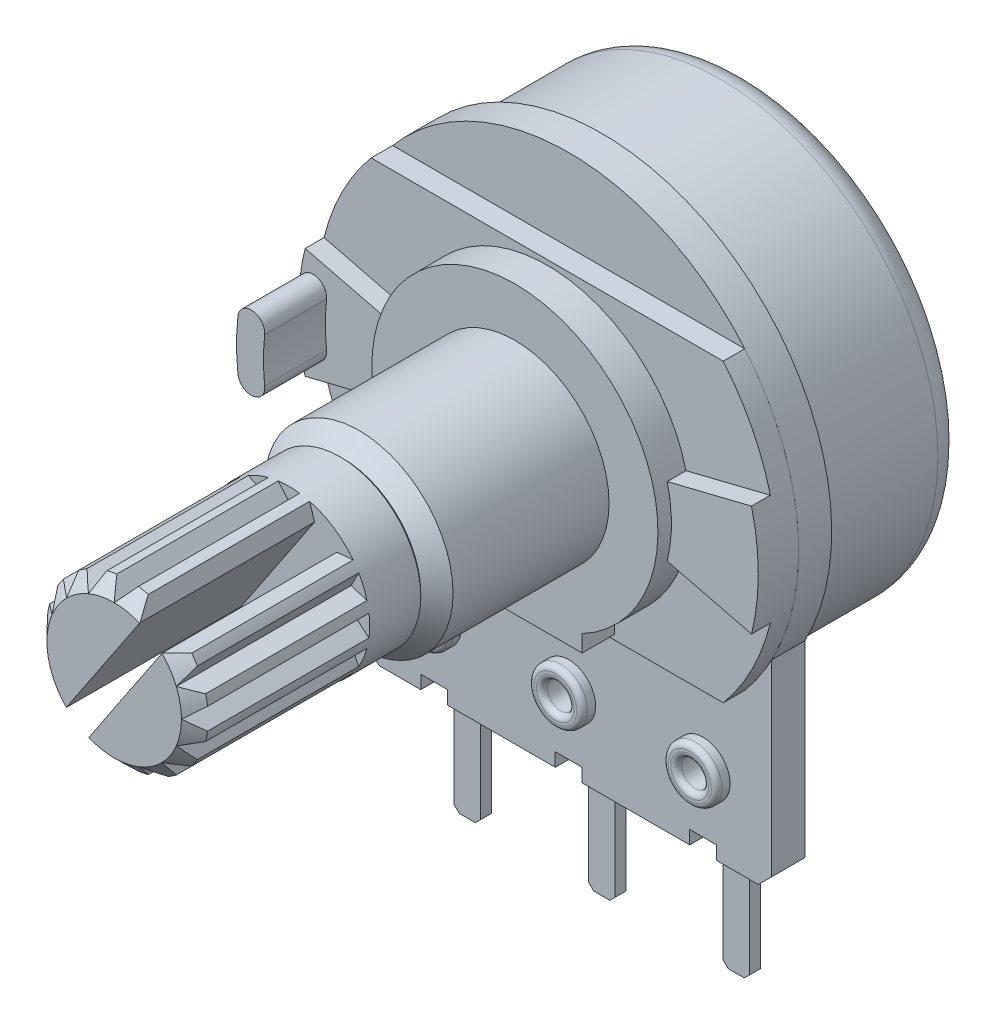
from build123d import *

# Parameters (mm, degrees)
SKETCH1_R               = 8.1
BOSS_EXTRUDE1_DEPTH     = 5.4
FILLET1_R               = 1
SHELL1_T                = -0.3
BOSS_EXTRUDE2_DEPTH     = 1.23
CHAMFER1_SIZE           = 0.5
BOSS_EXTRUDE3_DEPTH     = 0.8
BOSS_EXTRUDE4_DEPTH     = 1.2
BOSS_EXTRU_1_DEPTH      = 0.7
BOSS_EXTRU_2_DEPTH      = 2.3
SKETCH5_R               = 3.5
BOSS_EXTRUDE5_DEPTH     = 6.4
SKETCH6_R               = 2.3
CUT_EXTRUDE1_DEPTH      = 6
SKETCH7_R               = 2.25
BOSS_EXTRUDE6_DEPTH     = 6.2
CHAMFER2_SIZE           = 0.6
SKETCH9_R               = 2.75
BOSS_EXTRUDE8_DEPTH     = 0.1
SKETCH10_R              = 3
BOSS_EXTRUDE9_DEPTH     = 8.4
CHAMFER3_SIZE           = 0.5
CUT_EXTRUDE3_DEPTH      = 6.5
CIRPATTERN1_COUNT       = 16
SKETCH14_R              = 1
BOSS_EXTRUDE10_DEPTH    = 0.5
BOSS_EXTRUDE10_2_DEPTH  = 0.5
BOSS_EXTRUDE10_3_DEPTH  = 0.5
SKETCH15_R              = 0.75
CUT_EXTRUDE5_DEPTH      = 23.157673614
ESQUISSE3_R             = 0.725
BOSS_EXTRU_3_DEPTH      = 1.23
ESQUISSE4_R             = 0.5
ENL_V_MAT_EXTRU_1_DEPTH = 1.73
FILLET3_R               = 0.2
CONG_1_R                = 0.2
CONG_2_R                = 0.2
SKETCH16_W              = 1
SKETCH16_H              = 1
CUT_EXTRUDE6_DEPTH      = 1.23
SKETCH18_W              = 12.55
SKETCH18_H              = 1
CUT_EXTRUDE7_DEPTH      = 10
SKETCH24_W              = 1.5
SKETCH24_H              = 6.43597768
BOSS_EXTRUDE18_DEPTH    = 0.4
BOSS_EXTRUDE18_2_DEPTH  = 0.4
BOSS_EXTRUDE18_3_DEPTH  = 0.4
SKETCH25_W              = 1
SKETCH25_H              = 0.4
BOSS_EXTRUDE19_DEPTH    = 4
CHAMFER4_SIZE           = 0.2
CHAMFER5_SIZE           = 0.2
CHAMFER6_SIZE           = 0.2
SKETCH26_R              = 0.5
CUT_EXTRUDE9_DEPTH      = 0.4
CUT_EXTRUDE11_DEPTH     = 6.5


with BuildPart() as part:
    # Sketch1 → Boss-Extrude1 (new body)
    with BuildSketch(Plane.XY):
        with Locations(Location((0, 0, 0), (0, 0, 180))):
            Circle(SKETCH1_R)
    extrude(amount=BOSS_EXTRUDE1_DEPTH)

    # Fillet1
    fillet1_edges = [part.edges().sort_by_distance(p)[0] for p in [
        (8.1, 0, 0),
    ]]
    fillet(fillet1_edges, radius=FILLET1_R)

    # Shell1
    shell1_openings = [part.faces().sort_by_distance(p)[0] for p in [
        (0, 0, 5.4),
    ]]
    offset(amount=SHELL1_T, openings=shell1_openings, kind=Kind.INTERSECTION)

    # Sketch18 → Cut-Extrude7 (cut)
    with BuildSketch(Plane.XZ.offset(11.5)):
        with Locations((0, 4.9)):
            Rectangle(SKETCH18_W, SKETCH18_H)
    extrude(amount=-CUT_EXTRUDE7_DEPTH, mode=Mode.SUBTRACT)


with BuildPart() as body_2:
    # Sketch2 → Boss-Extrude2 (new body)
    with BuildSketch(Plane.XY.offset(5.4)):
        with BuildLine():
            Line((-7.55, -4.01248053), (-7.55, -11.5))
            Line((-7.55, -11.5), (7.55, -11.5))
            Line((7.55, -11.5), (7.55, -4.01248053))
            ThreePointArc((7.55, -4.01248053), (0, 8.55), (-7.55, -4.01248053))
        make_face()
    extrude(amount=BOSS_EXTRUDE2_DEPTH)

    # Chamfer1
    chamfer1_edges = [body_2.edges().sort_by_distance(p)[0] for p in [
        (7.55, -11.5, 6.015),
        (-7.55, -11.5, 6.015),
    ]]
    chamfer(chamfer1_edges, length=CHAMFER1_SIZE)

    # Sketch15 → Cut-Extrude5 (cut, through all)
    with BuildSketch(Plane.XY.offset(6.63)):
        with Locations((-5, -8.78201116)):
            Circle(SKETCH15_R)
        with Locations((0, -8.78201116)):
            Circle(SKETCH15_R)
        with Locations((5, -8.78201116)):
            Circle(SKETCH15_R)
    extrude(amount=-CUT_EXTRUDE5_DEPTH, mode=Mode.SUBTRACT)

    # Sketch16 → Cut-Extrude6 (cut)
    with BuildSketch(Plane.XY.offset(6.63)):
        with Locations((-5, -11.5)):
            Rectangle(SKETCH16_W, SKETCH16_H)
        with Locations((0, -11.5)):
            Rectangle(SKETCH16_W, SKETCH16_H)
        with Locations((5, -11.5)):
            Rectangle(SKETCH16_W, SKETCH16_H)
    extrude(amount=-CUT_EXTRUDE6_DEPTH, mode=Mode.SUBTRACT)


with BuildPart() as body_3:
    # Sketch3 → Boss-Extrude3 (new body)
    with BuildSketch(Plane.XY.offset(6.63)):
        with BuildLine():
            Line((-6.546182093, 5.5), (6.546182093, 5.5))
            ThreePointArc((6.546182093, 5.5), (8.55, 0), (6.546182093, -5.5))
            Line((6.546182093, -5.5), (-6.546182093, -5.5))
            ThreePointArc((-6.546182093, -5.5), (-8.55, 0), (-6.546182093, 5.5))
        make_face()
    extrude(amount=BOSS_EXTRUDE3_DEPTH)

    # Sketch4 → Boss-Extrude4 (add)
    with BuildSketch(Plane.XY.offset(7.43)):
        with BuildLine():
            Line((2.5, -4.695998296), (2.5, -5.32))
            Line((2.5, -5.32), (-2.5, -5.32))
            Line((-2.5, -5.32), (-2.5, -4.695998296))
            ThreePointArc((-2.5, -4.695998296), (0, 5.32), (2.5, -4.695998296))
        make_face()
    extrude(amount=BOSS_EXTRUDE4_DEPTH)

    # Esquisse1 → Boss.-Extru.1 (add)
    with BuildSketch(Plane.XY.offset(7.43)):
        with BuildLine():
            Line((-5.163278583, 1.281777778), (-8.298126295, 2.06))
            ThreePointArc((-8.298126295, 2.06), (-8.55, 0), (-8.298126295, -2.06))
            Line((-8.298126295, -2.06), (-5.163278583, -1.281777778))
            ThreePointArc((-5.163278583, -1.281777778), (-5.32, 0), (-5.163278583, 1.281777778))
        make_face()
        with BuildLine():
            Line((5.163278583, 1.281777778), (8.298126295, 2.06))
            ThreePointArc((8.298126295, 2.06), (8.55, 0), (8.298126295, -2.06))
            Line((8.298126295, -2.06), (5.163278583, -1.281777778))
            ThreePointArc((5.163278583, -1.281777778), (5.32, 0), (5.163278583, 1.281777778))
        make_face()
    extrude(amount=BOSS_EXTRU_1_DEPTH)

    # Esquisse2 → Boss.-Extru.2 (add)
    with BuildSketch(Plane.XY.offset(8.13)):
        with BuildLine():
            ThreePointArc((-8.499341893, 0.929347826), (-8.55, 0), (-8.499341893, -0.929347826))
            ThreePointArc((-8.499341893, -0.929347826), (-7.94795653, -1.372037538), (-7.505266818, -0.820652174))
            ThreePointArc((-7.505266818, -0.820652174), (-7.55, 0), (-7.505266818, 0.820652174))
            ThreePointArc((-7.505266818, 0.820652174), (-7.94795653, 1.372037538), (-8.499341893, 0.929347826))
        make_face()
    extrude(amount=BOSS_EXTRU_2_DEPTH)

    # Sketch5 → Boss-Extrude5 (add)
    with BuildSketch(Plane.XY.offset(8.63)):
        Circle(SKETCH5_R)
    extrude(amount=BOSS_EXTRUDE5_DEPTH)

    # Sketch6 → Cut-Extrude1 (cut)
    with BuildSketch(Plane.XY.offset(15.03)):
        Circle(SKETCH6_R)
    extrude(amount=-CUT_EXTRUDE1_DEPTH, mode=Mode.SUBTRACT)

    # Sketch7 → Boss-Extrude6 (add)
    with BuildSketch(Plane.XY.offset(8.63)):
        with Locations(Location((0, 0, 0), (0, 0, 180))):
            Circle(SKETCH7_R)
    extrude(amount=BOSS_EXTRUDE6_DEPTH)

    # Chamfer2
    chamfer2_edges = [body_3.edges().sort_by_distance(p)[0] for p in [
        (-3.5, 0, 15.03),
    ]]
    chamfer(chamfer2_edges, length=CHAMFER2_SIZE)

    # Sketch9 → Boss-Extrude8 (add)
    with BuildSketch(Plane.XY.offset(15.03)):
        Circle(SKETCH9_R)
    extrude(amount=BOSS_EXTRUDE8_DEPTH)

    # Sketch10 → Boss-Extrude9 (add)
    with BuildSketch(Plane.XY.offset(15.13)):
        Circle(SKETCH10_R)
    extrude(amount=BOSS_EXTRUDE9_DEPTH)

    # Chamfer3
    chamfer3_edges = [body_3.edges().sort_by_distance(p)[0] for p in [
        (-3, 0, 23.53),
    ]]
    chamfer(chamfer3_edges, length=CHAMFER3_SIZE)

    # Sketch12 → Cut-Extrude3 (cut)
    with BuildSketch(Plane.XY.offset(23.53)):
        with BuildLine():
            Line((-0.4, 2.973213749), (0, 2.5))
            Line((0, 2.5), (0.4, 2.973213749))
            ThreePointArc((0.4, 2.973213749), (0, 3), (-0.4, 2.973213749))
        make_face()
    cut_extrude3 = extrude(amount=-CUT_EXTRUDE3_DEPTH, mode=Mode.SUBTRACT)

    # CirPattern1: Cut-Extrude3 ×16 about axis
    cirpattern1_axis = Axis((0, 0, 0), (0, 0, 1))
    for i in range(1, CIRPATTERN1_COUNT):
        add(cut_extrude3.rotate(cirpattern1_axis, i * 360 / CIRPATTERN1_COUNT), mode=Mode.SUBTRACT)

    # Sketch28 → Cut-Extrude11 (cut)
    with BuildSketch(Plane.XY.offset(23.53)):
        Polygon((-1.250975893, -2.772193953), (2.082445505, 2.21662372), (1.250975893, 2.772193953), (-2.082445505, -2.21662372), align=None)
    extrude(amount=-CUT_EXTRUDE11_DEPTH, mode=Mode.SUBTRACT)


with BuildPart() as body_4:
    # Sketch14 → Boss-Extrude10 (new body)
    with BuildSketch(Plane.XY.offset(6.63)):
        with Locations((-5, -8.78201116)):
            Circle(SKETCH14_R)
    extrude(amount=BOSS_EXTRUDE10_DEPTH)



with BuildPart() as body_5:
    # Sketch14 → Boss-Extrude10 2 (new body)
    with BuildSketch(Plane.XY.offset(6.63)):
        with Locations((0, -8.78201116)):
            Circle(SKETCH14_R)
    extrude(amount=BOSS_EXTRUDE10_2_DEPTH)


with BuildPart() as body_6:
    # Sketch14 → Boss-Extrude10 3 (new body)
    with BuildSketch(Plane.XY.offset(6.63)):
        with Locations((5, -8.78201116)):
            Circle(SKETCH14_R)
    extrude(amount=BOSS_EXTRUDE10_3_DEPTH)


with BuildPart() as body_4_1:
    add(body_4.part)

    add(body_5.part)  # Boss.-Extru.3 merges body 5

    add(body_6.part)  # Boss.-Extru.3 merges body 6
    # Esquisse3 → Boss.-Extru.3 (add)
    with BuildSketch(Plane(origin=(0, 0, 6.63), x_dir=(-1, 0, 0), z_dir=(0, 0, -1))):
        with Locations(Location((5, -8.78201116, 0), (0, 0, 180))):
            Circle(ESQUISSE3_R)
        with Locations(Location((0, -8.78201116, 0), (0, 0, 180))):
            Circle(ESQUISSE3_R)
        with Locations(Location((-5, -8.78201116, 0), (0, 0, 180))):
            Circle(ESQUISSE3_R)
    extrude(amount=BOSS_EXTRU_3_DEPTH)

    # Esquisse4 → Enlèv. mat.-Extru.1 (cut)
    with BuildSketch(Plane.XY.offset(7.13)):
        with Locations((-5, -8.78201116)):
            Circle(ESQUISSE4_R)
        with Locations((0, -8.78201116)):
            Circle(ESQUISSE4_R)
        with Locations((5, -8.78201116)):
            Circle(ESQUISSE4_R)
    extrude(amount=-ENL_V_MAT_EXTRU_1_DEPTH, mode=Mode.SUBTRACT)

    # Fillet3
    fillet3_edges = [body_4_1.edges().sort_by_distance(p)[0] for p in [
        (-5.5, -8.78201116, 7.13),
        (-6, -8.78201116, 7.13),
    ]]
    fillet(fillet3_edges, radius=FILLET3_R)

    # Congé1
    cong_1_edges = [body_4_1.edges().sort_by_distance(p)[0] for p in [
        (-0.5, -8.78201116, 7.13),
        (-1, -8.78201116, 7.13),
    ]]
    fillet(cong_1_edges, radius=CONG_1_R)

    # Congé2
    cong_2_edges = [body_4_1.edges().sort_by_distance(p)[0] for p in [
        (4.5, -8.78201116, 7.13),
        (4, -8.78201116, 7.13),
    ]]
    fillet(cong_2_edges, radius=CONG_2_R)


with BuildPart() as body_5_2:
    # Sketch24 → Boss-Extrude18 (new body)
    with BuildSketch(Plane(origin=(0, 0, 5.4), x_dir=(-1, 0, 0), z_dir=(0, 0, -1))):
        with Locations((-5, -8.78201116)):
            Rectangle(SKETCH24_W, SKETCH24_H)
    extrude(amount=BOSS_EXTRUDE18_DEPTH)



with BuildPart() as body_6_2:
    # Sketch24 → Boss-Extrude18 2 (new body)
    with BuildSketch(Plane(origin=(0, 0, 5.4), x_dir=(-1, 0, 0), z_dir=(0, 0, -1))):
        with Locations((0, -8.78201116)):
            Rectangle(SKETCH24_W, SKETCH24_H)
    extrude(amount=BOSS_EXTRUDE18_2_DEPTH)


with BuildPart() as body_7:
    # Sketch24 → Boss-Extrude18 3 (new body)
    with BuildSketch(Plane(origin=(0, 0, 5.4), x_dir=(-1, 0, 0), z_dir=(0, 0, -1))):
        with Locations((5, -8.78201116)):
            Rectangle(SKETCH24_W, SKETCH24_H)
    extrude(amount=BOSS_EXTRUDE18_3_DEPTH)


with BuildPart() as body_5_2_1:
    add(body_5_2.part)

    add(body_6_2.part)  # Boss-Extrude19 merges body 6 2

    add(body_7.part)  # Boss-Extrude19 merges body 7
    # Sketch25 → Boss-Extrude19 (add)
    with BuildSketch(Plane.XZ.offset(12)):
        with Locations((-5, 5.2)):
            Rectangle(SKETCH25_W, SKETCH25_H)
        with Locations((0, 5.2)):
            Rectangle(SKETCH25_W, SKETCH25_H)
        with Locations((5, 5.2)):
            Rectangle(SKETCH25_W, SKETCH25_H)
    extrude(amount=BOSS_EXTRUDE19_DEPTH)

    # Chamfer4
    chamfer4_edges = [body_5_2_1.edges().sort_by_distance(p)[0] for p in [
        (4.5, -16, 5.2),
        (5.5, -16, 5.2),
    ]]
    chamfer(chamfer4_edges, length=CHAMFER4_SIZE)

    # Chamfer5
    chamfer5_edges = [body_5_2_1.edges().sort_by_distance(p)[0] for p in [
        (-0.5, -16, 5.2),
        (0.5, -16, 5.2),
    ]]
    chamfer(chamfer5_edges, length=CHAMFER5_SIZE)

    # Chamfer6
    chamfer6_edges = [body_5_2_1.edges().sort_by_distance(p)[0] for p in [
        (-4.5, -16, 5.2),
        (-5.5, -16, 5.2),
    ]]
    chamfer(chamfer6_edges, length=CHAMFER6_SIZE)

    # Sketch26 → Cut-Extrude9 (cut)
    with BuildSketch(Plane.XY.offset(5.4)):
        with Locations((-5, -8.78201116)):
            Circle(SKETCH26_R)
        with Locations((0, -8.78201116)):
            Circle(SKETCH26_R)
        with Locations((5, -8.78201116)):
            Circle(SKETCH26_R)
    extrude(amount=-CUT_EXTRUDE9_DEPTH, mode=Mode.SUBTRACT)


solid = Compound([part.part, body_2.part, body_3.part, body_4_1.part, body_5_2_1.part])
